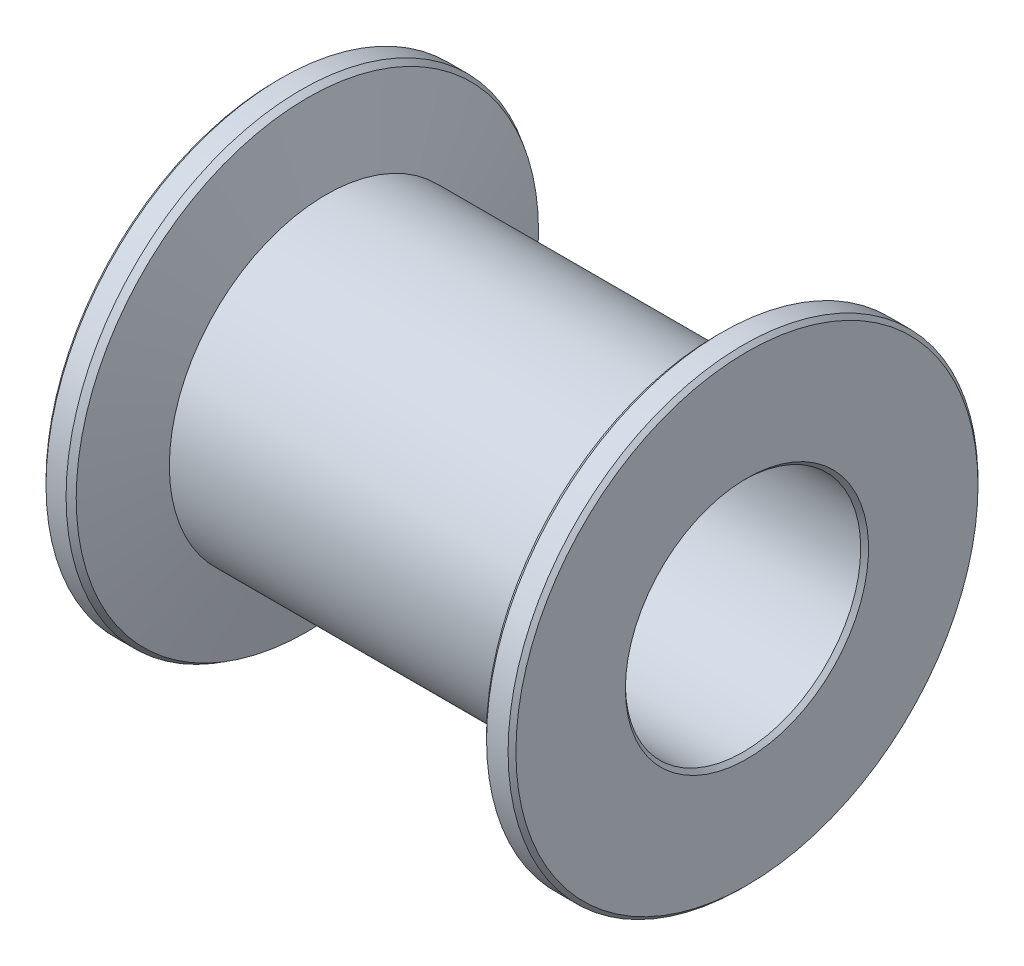
from build123d import *


with BuildPart() as part:
    # Sketch1 → Revolve1 (revolve)
    with BuildSketch(Plane(origin=(0, 0, 0), x_dir=(-1, 0, 0), z_dir=(0, 0, -1))):
        Polygon((5.387436854, 6), (5.225746437, 5.90298575), (4.75, 4), (-4.75, 4), (-5.216666667, 5.866666667), (-5.35, 6), (-5.9, 6), (-6, 5.9), (-6, 3.105), (-5.9, 3.005), (5.9, 3.005), (6, 3.105), (6, 5.9), (5.9, 6), align=None)
    revolve(axis=Axis((6, 0, 0), (-1, 0, 0)))


solid = part.part
